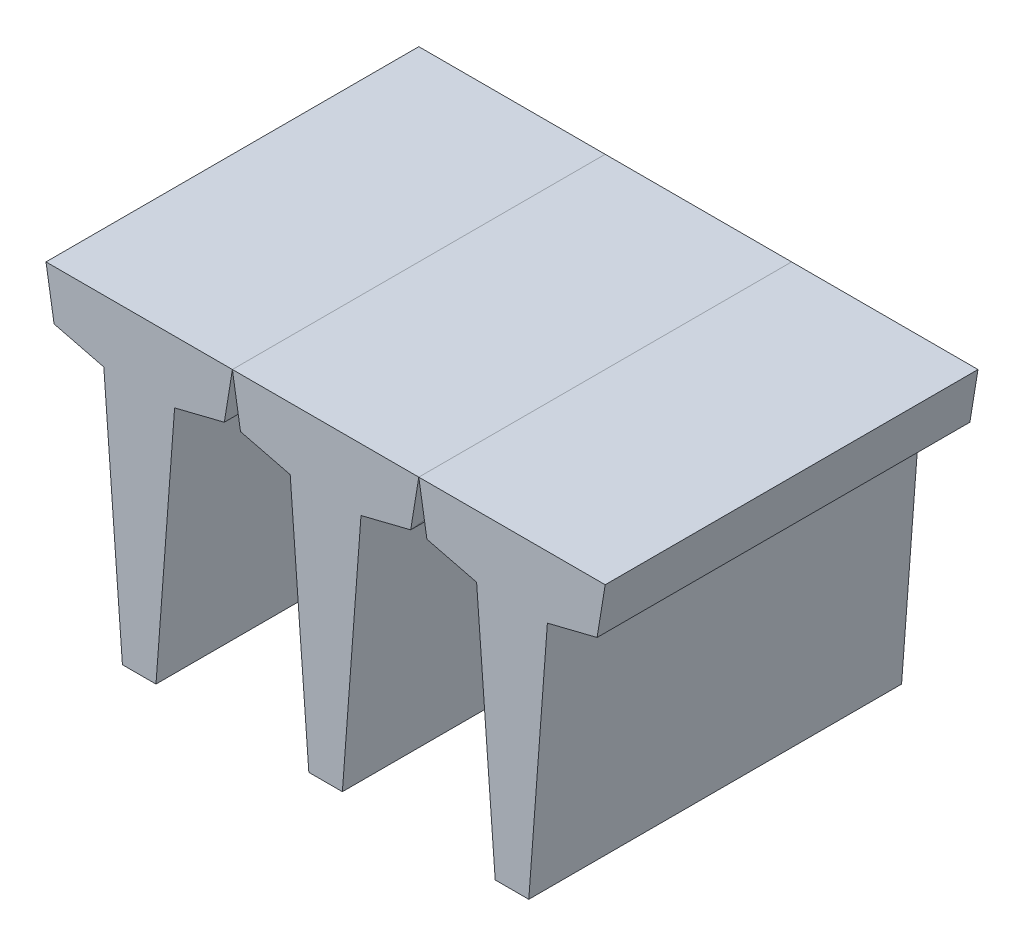
from build123d import *

# Parameters (mm, degrees)
BOSS_EXTRUDE1_DEPTH = 3000
LPATTERN1_COUNT     = 2
LPATTERN1_PITCH     = 1500
LPATTERN1_2_COUNT   = 2
LPATTERN1_2_PITCH   = 1500


with BuildPart() as part:
    # Sketch1 → Boss-Extrude1 (new body)
    with BuildSketch(Plane.XY):
        Polygon((-284.808780443, 151.37221549), (-135.024268123, -1848.62778451), (0, -1848.62778451), (0, 651.37221549), (-750, 651.37221549), (-684.808780443, 251.37221549), align=None)
        Polygon((0, 651.37221549), (0, -1848.62778451), (135.024268123, -1848.62778451), (284.808780443, 151.37221549), (684.808780443, 251.37221549), (750, 651.37221549), align=None)
    extrude(amount=BOSS_EXTRUDE1_DEPTH)


with BuildPart() as lpattern1_1:
    # LPattern1: pattern copy
    add(part.part.moved(Location(Vector(1, 0, 0) * (1 * LPATTERN1_PITCH))))


with BuildPart() as lpattern1_2_1:
    # LPattern1 2: pattern copy
    add(part.part.moved(Location(Vector(-1, 0, 0) * (1 * LPATTERN1_2_PITCH))))


with BuildPart() as lpattern1_2_2:
    # LPattern1 2: pattern copy
    add(lpattern1_1.part.moved(Location(Vector(-1, 0, 0) * (1 * LPATTERN1_2_PITCH))))


solid = Compound([part.part, lpattern1_1.part, lpattern1_2_1.part, lpattern1_2_2.part])
